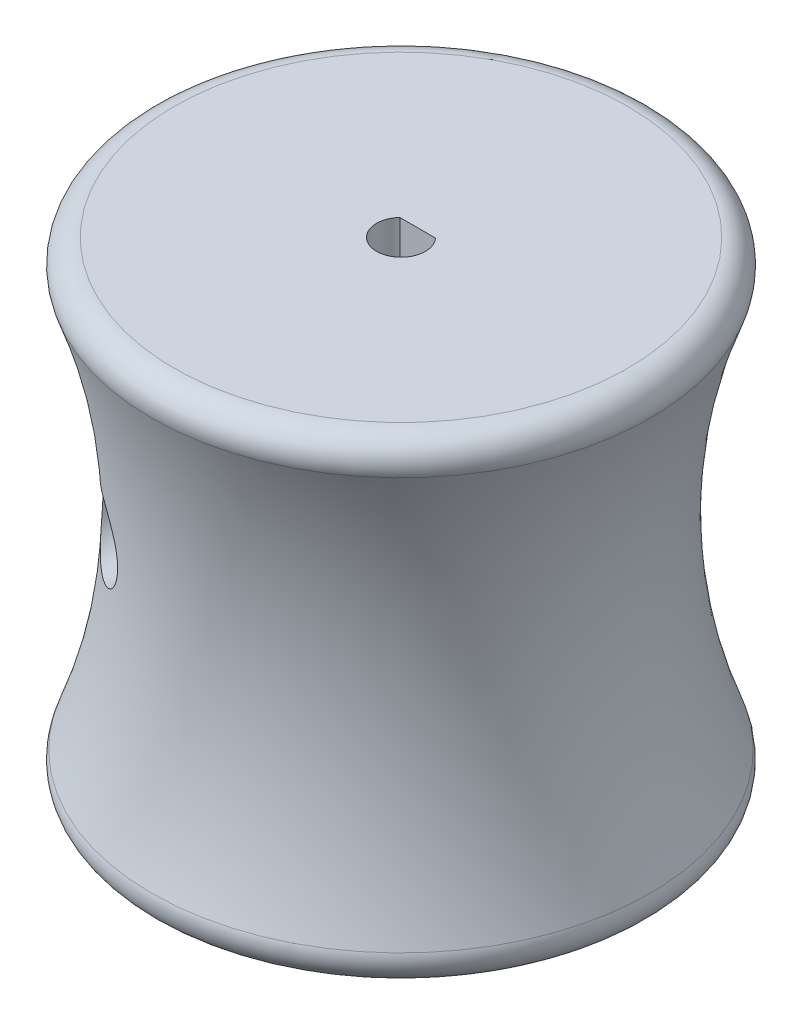
from build123d import *

# Parameters (mm, degrees)
CONG_1_R                     = 2
BOSS_EXTRU_1_DEPTH           = 40
ESQUISSE3_R                  = 3
ENL_V_MAT_EXTRU_1_DEPTH      = 22.074664225
ENL_V_MAT_EXTRU_1_DEPTH_BACK = 22.074664225


with BuildPart() as part:
    # Esquisse1 → Révolution1 (revolve)
    with BuildSketch(Plane.XY):
        with BuildLine():
            Line((-2.05, 0), (-2.05, 40))
            Line((-2.05, 40), (-22.05, 40))
            ThreePointArc((-22.05, 40), (-17.818604845, 20), (-22.05, 0))
            Line((-22.05, 0), (-2.05, 0))
        make_face()
    revolve(axis=Axis((0, 0, 0), (0, 1, 0)))

    # Congé1
    cong_1_edges = [part.edges().sort_by_distance(p)[0] for p in [
        (22.05, 40, 0),
        (22.05, 0, 0),
    ]]
    fillet(cong_1_edges, radius=CONG_1_R)

    # Esquisse2 → Boss.-Extru.1 (add)
    with BuildSketch(Plane(origin=(0, 40, 0), x_dir=(1, 0, 0), z_dir=(0, 1, 0))):
        with BuildLine():
            Line((-1.5, 1.397318861), (1.5, 1.397318861))
            ThreePointArc((1.5, 1.397318861), (0, 2.05), (-1.5, 1.397318861))
        make_face()
    extrude(amount=-BOSS_EXTRU_1_DEPTH)

    # Esquisse3 → Enlèv. mat.-Extru.1 (cut, two sides)
    with BuildSketch(Plane.XY) as enl_v_mat_extru_1_sk:
        with Locations((-10.821847214, 20)):
            Circle(ESQUISSE3_R)
    extrude(amount=ENL_V_MAT_EXTRU_1_DEPTH, mode=Mode.SUBTRACT)
    extrude(enl_v_mat_extru_1_sk.sketch, amount=-ENL_V_MAT_EXTRU_1_DEPTH_BACK, mode=Mode.SUBTRACT)


solid = part.part
